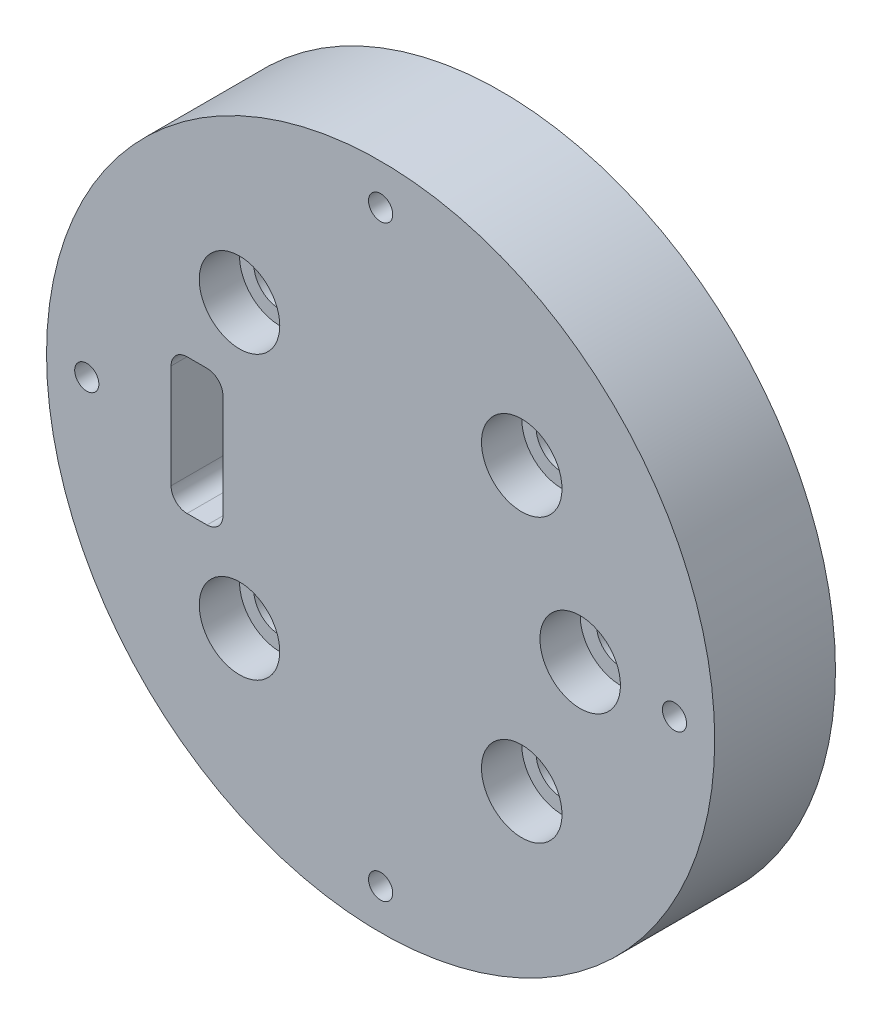
from build123d import *

# Parameters (mm, degrees)
SKETCH_1_R           = 41.5
EXTRUDE_1_DEPTH      = 5
EXTRUDE_1_DEPTH_BACK = 10
SKETCH_2_R           = 5
CUT_EXTRUDE_1_DEPTH  = 5
SKETCH_4_R           = 1.5
CUT_EXTRUDE_2_DEPTH  = 16


with BuildPart() as part:
    # 草图1 → 凸台-拉伸1 (new body, two sides)
    with BuildSketch(Plane.XY) as extrude_1_sk:
        Circle(SKETCH_1_R)
        with BuildLine():
            ThreePointArc((-20.75113276, -17.528548354), (-17.528548354, -14.305963949), (-14.305963949, -17.528548354))
            ThreePointArc((-14.305963949, -17.528548354), (-17.528548354, -20.75113276), (-20.75113276, -17.528548354))
        make_face(mode=Mode.SUBTRACT)
        with BuildLine():
            ThreePointArc((14.305963949, -17.528548354), (17.528548354, -14.305963949), (20.75113276, -17.528548354))
            ThreePointArc((20.75113276, -17.528548354), (17.528548354, -20.75113276), (14.305963949, -17.528548354))
        make_face(mode=Mode.SUBTRACT)
        with BuildLine():
            Line((-24.045437487, 8.428297676), (-21.566526406, 8.428297676))
            ThreePointArc((-21.566526406, 8.428297676), (-20.68362959, 8.220920288), (-19.985383241, 7.642159365))
            ThreePointArc((-19.985383241, 7.642159365), (-19.686578169, 7.076512396), (-19.583397541, 6.445168811))
            Line((-19.583397541, 6.445168811), (-19.583397541, -6.445168811))
            ThreePointArc((-19.583397541, -6.445168811), (-20.164242538, -7.847452679), (-21.566526406, -8.428297676))
            Line((-21.566526406, -8.428297676), (-24.045437487, -8.428297676))
            ThreePointArc((-24.045437487, -8.428297676), (-25.447721356, -7.847452679), (-26.028566352, -6.445168811))
            Line((-26.028566352, -6.445168811), (-26.028566352, 6.445168811))
            ThreePointArc((-26.028566352, 6.445168811), (-25.447721356, 7.847452679), (-24.045437487, 8.428297676))
        make_face(mode=Mode.SUBTRACT)
        with BuildLine():
            ThreePointArc((-20.75113276, 17.528548354), (-17.528548354, 20.75113276), (-14.305963949, 17.528548354))
            ThreePointArc((-14.305963949, 17.528548354), (-17.528548354, 14.305963949), (-20.75113276, 17.528548354))
        make_face(mode=Mode.SUBTRACT)
        with BuildLine():
            ThreePointArc((14.305963949, 17.528548354), (17.528548354, 20.75113276), (20.75113276, 17.528548354))
            ThreePointArc((20.75113276, 17.528548354), (17.528548354, 14.305963949), (14.305963949, 17.528548354))
        make_face(mode=Mode.SUBTRACT)
        with BuildLine():
            ThreePointArc((21.814417514, 0), (24.789110812, 2.974693297), (27.763804109, 0))
            ThreePointArc((27.763804109, 0), (24.789110812, -2.974693297), (21.814417514, 0))
        make_face(mode=Mode.SUBTRACT)
    extrude(amount=EXTRUDE_1_DEPTH)
    extrude(extrude_1_sk.sketch, amount=-EXTRUDE_1_DEPTH_BACK)

    # 草图2 → 切除-拉伸1 (cut)
    with BuildSketch(Plane.XY.offset(5)):
        with Locations((-17.528548354, 17.528548354)):
            Circle(SKETCH_2_R)
        with BuildLine():
            ThreePointArc((-20.75113276, 17.528548354), (-17.528548354, 14.305963949), (-14.305963949, 17.528548354))
            ThreePointArc((-14.305963949, 17.528548354), (-17.528548354, 20.75113276), (-20.75113276, 17.528548354))
        make_face(mode=Mode.SUBTRACT)
        with Locations((17.528548354, 17.528548354)):
            Circle(SKETCH_2_R)
        with BuildLine():
            ThreePointArc((20.75113276, 17.528548354), (17.528548354, 20.75113276), (14.305963949, 17.528548354))
            ThreePointArc((14.305963949, 17.528548354), (17.528548354, 14.305963949), (20.75113276, 17.528548354))
        make_face(mode=Mode.SUBTRACT)
        with Locations((-17.528548354, -17.528548354)):
            Circle(SKETCH_2_R)
        with BuildLine():
            ThreePointArc((-20.75113276, -17.528548354), (-17.528548354, -20.75113276), (-14.305963949, -17.528548354))
            ThreePointArc((-14.305963949, -17.528548354), (-17.528548354, -14.305963949), (-20.75113276, -17.528548354))
        make_face(mode=Mode.SUBTRACT)
        with Locations((17.528548354, -17.528548354)):
            Circle(SKETCH_2_R)
        with BuildLine():
            ThreePointArc((14.305963949, -17.528548354), (17.528548354, -20.75113276), (20.75113276, -17.528548354))
            ThreePointArc((20.75113276, -17.528548354), (17.528548354, -14.305963949), (14.305963949, -17.528548354))
        make_face(mode=Mode.SUBTRACT)
        with Locations((24.789110812, 0)):
            Circle(SKETCH_2_R)
        with BuildLine():
            ThreePointArc((21.814417514, 0), (24.789110812, -2.974693297), (27.763804109, 0))
            ThreePointArc((27.763804109, 0), (24.789110812, 2.974693297), (21.814417514, 0))
        make_face(mode=Mode.SUBTRACT)
    extrude(amount=-CUT_EXTRUDE_1_DEPTH, mode=Mode.SUBTRACT)

    # 草图4 → 切除-拉伸2 (cut, through all)
    with BuildSketch(Plane.XY.offset(5)):
        with Locations((-36.5, 0)):
            Circle(SKETCH_4_R)
        with Locations((0, -36.5)):
            Circle(SKETCH_4_R)
        with Locations((36.5, 0)):
            Circle(SKETCH_4_R)
        with Locations((0, 36.5)):
            Circle(SKETCH_4_R)
    extrude(amount=-CUT_EXTRUDE_2_DEPTH, mode=Mode.SUBTRACT)


solid = part.part
